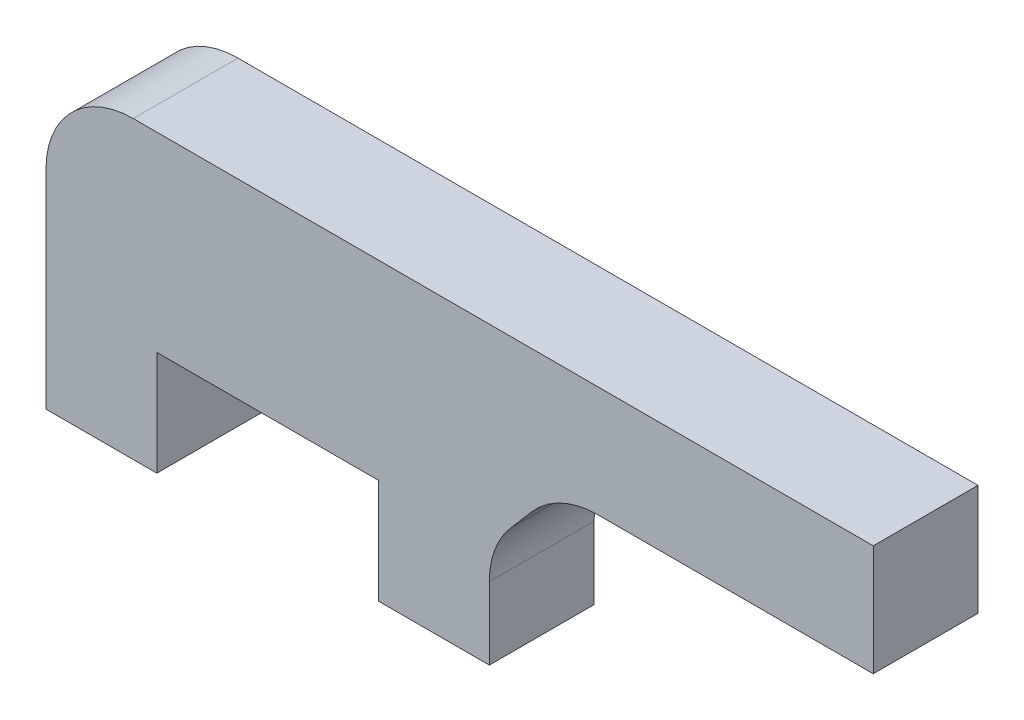
from build123d import *

# Parameters (mm, degrees)
BOSS_EXTRUDE1_DEPTH = 6


with BuildPart() as part:
    # Sketch1 → Boss-Extrude1 (new body)
    with BuildSketch(Plane.XY):
        with BuildLine():
            Line((684.689802479, 51.1944), (668.919080645, 51.1944))
            ThreePointArc((668.919080645, 51.1944), (666.832798953, 50.738344179), (665.127101625, 49.453371481))
            Line((665.127101625, 49.453371481), (663.897823459, 48.023043832))
            ThreePointArc((663.897823459, 48.023043832), (663.001524805, 46.501902162), (662.689802479, 44.764072351))
            Line((662.689802479, 44.764072351), (662.689802479, 40.62305))
            Line((662.689802479, 40.62305), (656.339802479, 40.62305))
            Line((656.339802479, 40.62305), (656.339802479, 46.61745))
            Line((656.339802479, 46.61745), (643.639802479, 46.61745))
            Line((643.639802479, 46.61745), (643.639802479, 40.62305))
            Line((643.639802479, 40.62305), (637.289802479, 40.62305))
            Line((637.289802479, 40.62305), (637.289802479, 52.5444))
            ThreePointArc((637.289802479, 52.5444), (638.754268573, 56.079933906), (642.289802479, 57.5444))
            Line((642.289802479, 57.5444), (662.689802479, 57.5444))
            Line((662.689802479, 57.5444), (684.689802479, 57.5444))
            Line((684.689802479, 57.5444), (684.689802479, 51.1944))
        make_face()
    extrude(amount=BOSS_EXTRUDE1_DEPTH)


solid = part.part
